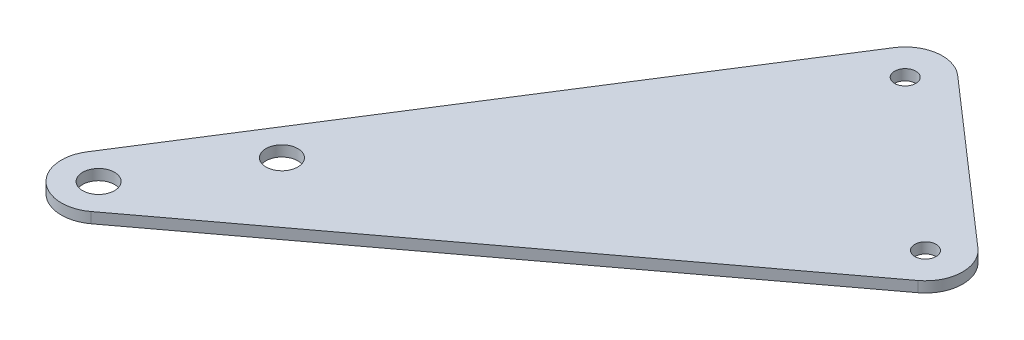
from build123d import *

# Parameters (mm, degrees)
SZKIC1_R                    = 2
SZKIC1_R_2                  = 3
DODANIE_WYCI_GNI_CIE1_DEPTH = 2


with BuildPart() as part:
    # Szkic1 → Dodanie-wyciągnięcie1 (new body)
    with BuildSketch(Plane(origin=(0, 0, 0), x_dir=(1, 0, 0), z_dir=(0, 1, 0))):
        with BuildLine():
            Line((1700.559122815, -953.967589017), (1789.615327329, -887.395203569))
            ThreePointArc((1789.615327329, -887.395203569), (1792.419138662, -882.05438434), (1790.028740764, -876.516180127))
            Line((1790.028740764, -876.516180127), (1759.900801977, -850.204446919))
            ThreePointArc((1759.900801977, -850.204446919), (1754.293249598, -848.549066517), (1749.385441114, -851.726855661))
            Line((1749.385441114, -851.726855661), (1690.457175388, -944.610974317))
            ThreePointArc((1690.457175388, -944.610974317), (1691.611316681, -953.496529428), (1700.559122815, -953.967589017))
        make_face()
        with Locations((1755.296248665, -855.476836207)):
            Circle(SZKIC1_R, mode=Mode.SUBTRACT)
        with Locations((1785.424187453, -881.788569415)):
            Circle(SZKIC1_R, mode=Mode.SUBTRACT)
        with Locations((1696.367982939, -948.360954863)):
            Circle(SZKIC1_R_2, mode=Mode.SUBTRACT)
        with Locations((1709.760770604, -927.250927896)):
            Circle(SZKIC1_R_2, mode=Mode.SUBTRACT)
    extrude(amount=DODANIE_WYCI_GNI_CIE1_DEPTH)


solid = part.part
